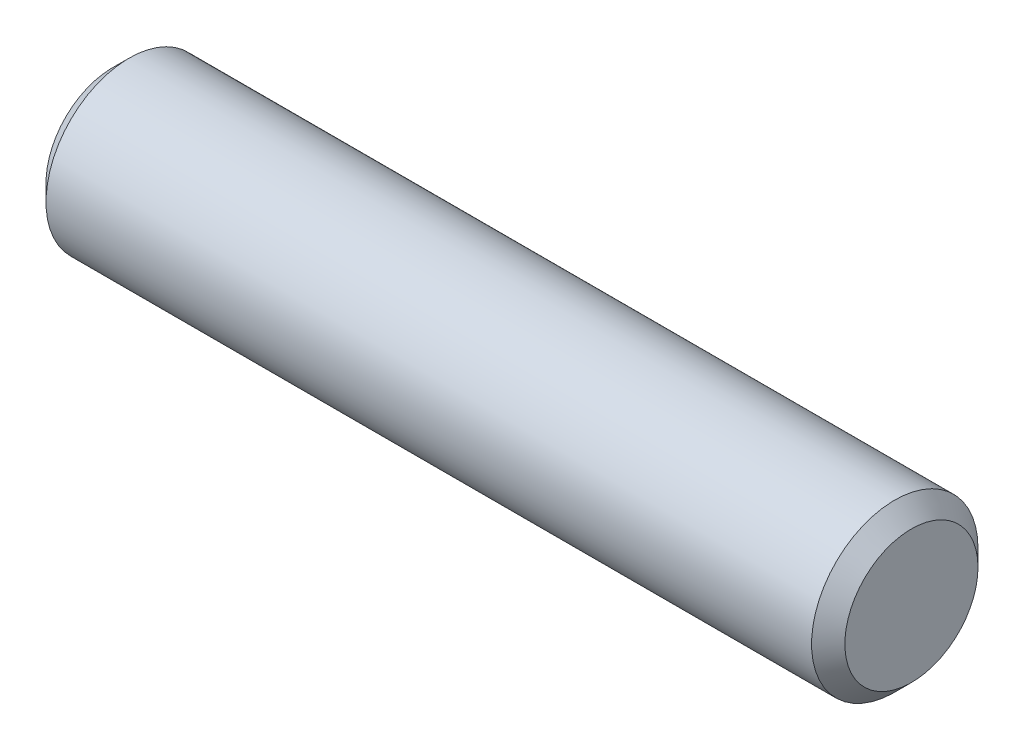
from build123d import *

# Parameters (mm, degrees)
SKETCH2_R           = 3.96875
EXTRUDE1_DEPTH      = 19.05
EXTRUDE1_DEPTH_BACK = 19.05
CHAMFER1_SIZE       = 0.79375


with BuildPart() as part:
    # Sketch2 → Extrude1 (new body, two sides)
    with BuildSketch(Plane(origin=(0, 0, 0), x_dir=(0, 0, -1), z_dir=(1, 0, 0))) as extrude1_sk:
        Circle(SKETCH2_R)
    extrude(amount=EXTRUDE1_DEPTH)
    extrude(extrude1_sk.sketch, amount=-EXTRUDE1_DEPTH_BACK)

    # Chamfer1
    chamfer1_edges = [part.edges().sort_by_distance(p)[0] for p in [
        (-19.05, 0, 3.96875),
        (19.05, 0, 3.96875),
    ]]
    chamfer(chamfer1_edges, length=CHAMFER1_SIZE)


solid = part.part
